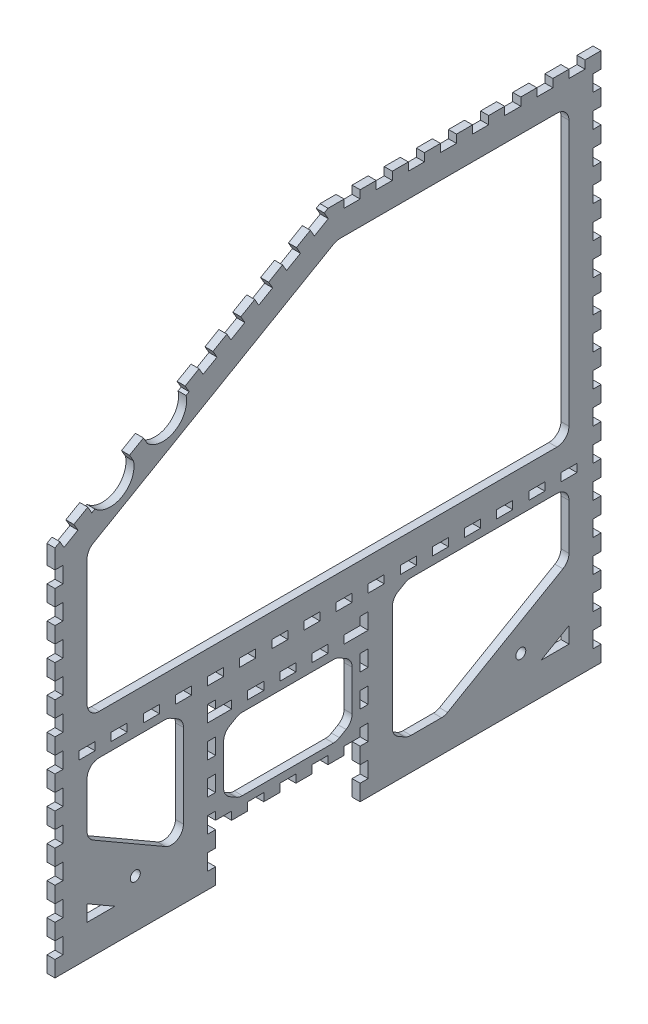
from build123d import *

# Parameters (mm, degrees)
BOSS_EXTRUDE1_DEPTH = 6.35
SKETCH3_R           = 3.96875
CUT_EXTRUDE1_DEPTH  = 7.35
SKETCH5_W           = 6.35
SKETCH5_H           = 12.7
CUT_EXTRUDE3_DEPTH  = 7.35
LPATTERN1_COUNT     = 16
LPATTERN1_PITCH     = 25.4
SKETCH6_W           = 6.35
SKETCH6_H           = 12.7
CUT_EXTRUDE4_DEPTH  = 7.35
LPATTERN2_COUNT     = 11
LPATTERN2_PITCH     = 25.4
SKETCH7_W           = 6.35
SKETCH7_H           = 12.7
SKETCH7_W_2         = 12.7
SKETCH7_H_2         = 6.35
CUT_EXTRUDE5_DEPTH  = 7.35
CUT_EXTRUDE6_DEPTH  = 7.35
LPATTERN3_COUNT     = 10
LPATTERN3_PITCH     = 25.4
SKETCH9_W           = 12.7
SKETCH9_H           = 6.35
CUT_EXTRUDE7_DEPTH  = 7.35
LPATTERN4_COUNT     = 8
LPATTERN4_PITCH     = 25.4
SKETCH10_R          = 3.175
CUT_EXTRUDE8_DEPTH  = 7.35
SKETCH11_R          = 3.96875
CUT_EXTRUDE9_DEPTH  = 7.35
SKETCH12_W          = 6.35
SKETCH12_H          = 12.7
CUT_EXTRUDE13_DEPTH = 7.35
CUT_EXTRUDE15_DEPTH = 7.35
CUT_EXTRUDE16_DEPTH = 7.35
SKETCH17_W          = 12.7
SKETCH17_H          = 6.35
CUT_EXTRUDE17_DEPTH = 7.35
LPATTERN5_COUNT     = 17
LPATTERN5_PITCH     = 25.4
LPATTERN6_COUNT     = 2
LPATTERN6_PITCH     = 120.65
SKETCH18_W          = 12.7
SKETCH18_H          = 6.35
CUT_EXTRUDE18_DEPTH = 7.35
LPATTERN7_COUNT     = 5
LPATTERN7_PITCH     = 25.4
CUT_EXTRUDE19_DEPTH = 7.35
SKETCH20_W          = 101.6
SKETCH20_H          = 57.15
CUT_EXTRUDE20_DEPTH = 7.35
CUT_EXTRUDE21_DEPTH = 7.35
CUT_EXTRUDE22_DEPTH = 7.35
BOSS_EXTRUDE4_DEPTH = 6.35
FILLET1_R           = 9.525


with BuildPart() as part:
    # Sketch2 → Boss-Extrude1 (new body)
    with BuildSketch(Plane(origin=(0, 0, 0), x_dir=(0, 0, -1), z_dir=(1, 0, 0))):
        Polygon((0, 0), (0, 294.450076882), (215.9, 419.1), (431.8, 419.1), (431.8, 0), (241.3, 0), (241.3, 38.1), (127, 38.1), (127, 0), align=None)
    extrude(amount=BOSS_EXTRUDE1_DEPTH)

    # Sketch3 → Cut-Extrude1 (cut, through all)
    with BuildSketch(Plane(origin=(6.35, 0, 0), x_dir=(0, 0, -1), z_dir=(1, 0, 0))):
        with Locations((63.5, 38.1)):
            Circle(SKETCH3_R)
        with Locations((368.3, 38.1)):
            Circle(SKETCH3_R)
    extrude(amount=-CUT_EXTRUDE1_DEPTH, mode=Mode.SUBTRACT)

    # Sketch5 → Cut-Extrude3 (cut, through all)
    with BuildSketch(Plane(origin=(6.35, 0, 0), x_dir=(0, 0, -1), z_dir=(1, 0, 0))):
        with Locations((428.625, 19.05)):
            Rectangle(SKETCH5_W, SKETCH5_H)
    cut_extrude3 = extrude(amount=-CUT_EXTRUDE3_DEPTH, mode=Mode.SUBTRACT)

    # LPattern1: Cut-Extrude3 ×16
    with Locations(*[(0, i * LPATTERN1_PITCH, 0) for i in range(1, LPATTERN1_COUNT)]):
        add(cut_extrude3, mode=Mode.SUBTRACT)

    # Sketch6 → Cut-Extrude4 (cut, through all)
    with BuildSketch(Plane(origin=(6.35, 0, 0), x_dir=(0, 0, -1), z_dir=(1, 0, 0))):
        with Locations((3.175, 19.05)):
            Rectangle(SKETCH6_W, SKETCH6_H)
    cut_extrude4 = extrude(amount=-CUT_EXTRUDE4_DEPTH, mode=Mode.SUBTRACT)

    # LPattern2: Cut-Extrude4 ×11
    with Locations(*[(0, i * LPATTERN2_PITCH, 0) for i in range(1, LPATTERN2_COUNT)]):
        add(cut_extrude4, mode=Mode.SUBTRACT)

    # Sketch7 → Cut-Extrude5 (cut, through all)
    with BuildSketch(Plane(origin=(6.35, 0, 0), x_dir=(0, 0, -1), z_dir=(1, 0, 0))):
        with Locations((123.825, 19.05)):
            Rectangle(SKETCH7_W, SKETCH7_H)
        with Locations((133.35, 41.275)):
            Rectangle(SKETCH7_W_2, SKETCH7_H_2)
        with Locations((158.75, 41.275)):
            Rectangle(SKETCH7_W_2, SKETCH7_H_2)
        with Locations((184.15, 41.275)):
            Rectangle(SKETCH7_W_2, SKETCH7_H_2)
        with Locations((244.475, 19.05)):
            Rectangle(SKETCH7_W, SKETCH7_H)
        with Locations((209.55, 41.275)):
            Rectangle(SKETCH7_W_2, SKETCH7_H_2)
        with Locations((234.95, 41.275)):
            Rectangle(SKETCH7_W_2, SKETCH7_H_2)
    extrude(amount=-CUT_EXTRUDE5_DEPTH, mode=Mode.SUBTRACT)

    # Sketch8 → Cut-Extrude6 (cut, through all)
    with BuildSketch(Plane(origin=(6.35, 0, 0), x_dir=(0, 0, -1), z_dir=(1, 0, 0))):
        Polygon((201.93507044, 411.037344159), (212.933593068, 417.387344159), (216.108593068, 411.888082845), (205.11007044, 405.538082845), align=None)
    cut_extrude6 = extrude(amount=-CUT_EXTRUDE6_DEPTH, mode=Mode.SUBTRACT)

    # LPattern3: Cut-Extrude6 ×10
    with Locations(*[Vector(0, -0.5, 0.866025404) * (i * LPATTERN3_PITCH) for i in range(1, LPATTERN3_COUNT)]):
        add(cut_extrude6, mode=Mode.SUBTRACT)

    # Sketch9 → Cut-Extrude7 (cut, through all)
    with BuildSketch(Plane(origin=(6.35, 0, 0), x_dir=(0, 0, -1), z_dir=(1, 0, 0))):
        with Locations((412.75, 415.925)):
            Rectangle(SKETCH9_W, SKETCH9_H)
    cut_extrude7 = extrude(amount=-CUT_EXTRUDE7_DEPTH, mode=Mode.SUBTRACT)

    # LPattern4: Cut-Extrude7 ×8
    with Locations(*[(0, 0, i * LPATTERN4_PITCH) for i in range(1, LPATTERN4_COUNT)]):
        add(cut_extrude7, mode=Mode.SUBTRACT)

    # Sketch10 → Cut-Extrude8 (cut, through all)
    with BuildSketch(Plane(origin=(6.35, 0, 0), x_dir=(0, 0, -1), z_dir=(1, 0, 0))):
        with Locations((222.25, 273.05)):
            Circle(SKETCH10_R)
        with Locations((222.25, 57.15)):
            Circle(SKETCH10_R)
        with Locations((146.05, 57.15)):
            Circle(SKETCH10_R)
        with Locations((146.05, 273.05)):
            Circle(SKETCH10_R)
    extrude(amount=-CUT_EXTRUDE8_DEPTH, mode=Mode.SUBTRACT)

    # Sketch11 → Cut-Extrude9 (cut, through all)
    with BuildSketch(Plane(origin=(6.35, 0, 0), x_dir=(0, 0, -1), z_dir=(1, 0, 0))):
        with Locations((38.1, 260.35)):
            Circle(SKETCH11_R)
        with Locations((266.7, 260.35)):
            Circle(SKETCH11_R)
    extrude(amount=-CUT_EXTRUDE9_DEPTH, mode=Mode.SUBTRACT)

    # Sketch12 → Cut-Extrude13 (cut, through all)
    with BuildSketch(Plane(origin=(6.35, 0, 0), x_dir=(0, 0, -1), z_dir=(1, 0, 0))):
        with Locations((123.825, 44.45)):
            Rectangle(SKETCH12_W, SKETCH12_H)
        with Locations((123.825, 69.85)):
            Rectangle(SKETCH12_W, SKETCH12_H)
        with Locations((123.825, 95.25)):
            Rectangle(SKETCH12_W, SKETCH12_H)
        with Locations((123.825, 120.65)):
            Rectangle(SKETCH12_W, SKETCH12_H)
    cut_extrude13 = extrude(amount=-CUT_EXTRUDE13_DEPTH, mode=Mode.SUBTRACT)

    # Sketch14 → Cut-Extrude15 (cut, through all)
    with BuildSketch(Plane(origin=(6.35, 0, 0), x_dir=(0, 0, -1), z_dir=(1, 0, 0))):
        Polygon((36.957231019, 315.787344159), (47.955753647, 322.137344159), (51.130753647, 316.638082845), (40.132231019, 310.288082845), align=None)
        Polygon((80.951321531, 341.187344159), (91.949844159, 347.537344159), (95.124844159, 342.038082845), (84.126321531, 335.688082845), align=None)
    extrude(amount=-CUT_EXTRUDE15_DEPTH, mode=Mode.SUBTRACT)

    # Sketch15 → Cut-Extrude16 (cut, through all)
    with BuildSketch(Plane(origin=(6.35, 0, 0), x_dir=(0, 0, -1), z_dir=(1, 0, 0))):
        with BuildLine():
            Line((62.129276275, 322.988082845), (31.558579521, 305.338082845))
            ThreePointArc((31.558579521, 305.338082845), (51.535904978, 302.314952438), (62.501260575, 319.285333297))
            ThreePointArc((62.501260575, 319.285333297), (62.408031035, 321.146027155), (62.129276275, 322.988082845))
        make_face()
        with BuildLine():
            Line((103.698495657, 346.988082845), (73.127798903, 329.338082845))
            ThreePointArc((73.127798903, 329.338082845), (93.10512436, 326.314952438), (104.070479957, 343.285333297))
            ThreePointArc((104.070479957, 343.285333297), (103.977250417, 345.146027155), (103.698495657, 346.988082845))
        make_face()
    extrude(amount=-CUT_EXTRUDE16_DEPTH, mode=Mode.SUBTRACT)

    # Sketch17 → Cut-Extrude17 (cut, through all)
    with BuildSketch(Plane(origin=(6.35, 0, 0), x_dir=(0, 0, -1), z_dir=(1, 0, 0))):
        with Locations((25.4, 142.875)):
            Rectangle(SKETCH17_W, SKETCH17_H)
    cut_extrude17 = extrude(amount=-CUT_EXTRUDE17_DEPTH, mode=Mode.SUBTRACT)

    # LPattern5: Cut-Extrude17 ×17
    with Locations(*[(0, 0, -i * LPATTERN5_PITCH) for i in range(1, LPATTERN5_COUNT)]):
        add(cut_extrude17, mode=Mode.SUBTRACT)

    # LPattern6: Cut-Extrude13 ×2
    with Locations(*[(0, 0, -i * LPATTERN6_PITCH) for i in range(1, LPATTERN6_COUNT)]):
        add(cut_extrude13, mode=Mode.SUBTRACT)

    # Sketch18 → Cut-Extrude18 (cut, through all)
    with BuildSketch(Plane(origin=(6.35, 0, 0), x_dir=(0, 0, -1), z_dir=(1, 0, 0))):
        with Locations((133.35, 117.475)):
            Rectangle(SKETCH18_W, SKETCH18_H)
    cut_extrude18 = extrude(amount=-CUT_EXTRUDE18_DEPTH, mode=Mode.SUBTRACT)

    # LPattern7: Cut-Extrude18 ×5
    with Locations(*[(0, 0, -i * LPATTERN7_PITCH) for i in range(1, LPATTERN7_COUNT)]):
        add(cut_extrude18, mode=Mode.SUBTRACT)

    # Sketch19 → Cut-Extrude19 (cut, through all)
    with BuildSketch(Plane(origin=(6.35, 0, 0), x_dir=(0, 0, -1), z_dir=(1, 0, 0))):
        Polygon((25.4, 279.785380045), (222.705909488, 393.7), (406.4, 393.7), (406.4, 165.1), (25.4, 165.1), align=None)
    extrude(amount=-CUT_EXTRUDE19_DEPTH, mode=Mode.SUBTRACT)

    # Sketch20 → Cut-Extrude20 (cut, through all)
    with BuildSketch(Plane(origin=(6.35, 0, 0), x_dir=(0, 0, -1), z_dir=(1, 0, 0))):
        with Locations((184.15, 79.375)):
            Rectangle(SKETCH20_W, SKETCH20_H)
    extrude(amount=-CUT_EXTRUDE20_DEPTH, mode=Mode.SUBTRACT)

    # Sketch21 → Cut-Extrude21 (cut, through all)
    with BuildSketch(Plane(origin=(6.35, 0, 0), x_dir=(0, 0, -1), z_dir=(1, 0, 0))):
        Polygon((266.7, 25.4), (308.202954744, 25.4), (406.4, 82.094090512), (406.4, 133.35), (266.7, 133.35), align=None)
        Polygon((25.4, 133.35), (25.4, 82.094090512), (101.6, 38.1), (101.6, 133.35), align=None)
        Polygon((25.4, 38.1), (25.4, 25.4), (47.397045256, 25.4), align=None)
    extrude(amount=-CUT_EXTRUDE21_DEPTH, mode=Mode.SUBTRACT)

    # Sketch22 → Cut-Extrude22 (cut, through all)
    with BuildSketch(Plane(origin=(6.35, 0, 0), x_dir=(0, 0, -1), z_dir=(1, 0, 0))):
        Polygon((384.402954744, 25.4), (406.4, 38.1), (406.4, 25.4), align=None)
    extrude(amount=-CUT_EXTRUDE22_DEPTH, mode=Mode.SUBTRACT)

    # Sketch26 → Boss-Extrude4 (add, through all)
    with BuildSketch(Plane(origin=(6.35, 0, 0), x_dir=(0, 0, -1), z_dir=(1, 0, 0))):
        Polygon((266.7, 133.35), (266.7, 126.280871047), (278.944090512, 133.35), align=None)
        Polygon((89.355909488, 133.35), (101.6, 126.280871047), (101.6, 133.35), align=None)
        Polygon((266.7, 32.469128953), (278.944090512, 25.4), (266.7, 25.4), align=None)
        Polygon((133.35, 107.95), (133.35, 100.880871047), (145.594090512, 107.95), align=None)
        Polygon((234.95, 107.95), (222.705909488, 107.95), (234.95, 100.880871047), align=None)
        Polygon((133.35, 50.8), (145.594090512, 50.8), (133.35, 57.869128953), align=None)
        Polygon((234.95, 50.8), (222.705909488, 50.8), (234.95, 57.869128953), align=None)
    extrude(amount=-BOSS_EXTRUDE4_DEPTH)

    # Fillet1
    fillet1_edges = [part.edges().sort_by_distance(p)[0] for p in [
        (3.175, 165.1, -25.4),
        (3.175, 279.785380045, -25.4),
        (3.175, 393.7, -222.705909488),
        (3.175, 393.7, -406.4),
        (3.175, 165.1, -406.4),
        (3.175, 133.35, -406.4),
        (3.175, 82.094090512, -406.4),
        (3.175, 25.4, -308.202954744),
        (3.175, 133.35, -25.4),
        (3.175, 38.1, -101.6),
        (3.175, 82.094090512, -25.4),
        (3.175, 133.35, -278.944090512),
        (3.175, 126.280871047, -266.7),
        (3.175, 100.880871047, -234.95),
        (3.175, 107.95, -222.705909488),
        (3.175, 133.35, -89.355909488),
        (3.175, 126.280871047, -101.6),
        (3.175, 32.469128953, -266.7),
        (3.175, 25.4, -278.944090512),
        (3.175, 107.95, -145.594090512),
        (3.175, 100.880871047, -133.35),
        (3.175, 57.869128953, -133.35),
        (3.175, 50.8, -145.594090512),
        (3.175, 57.869128953, -234.95),
        (3.175, 50.8, -222.705909488),
    ]]
    fillet(fillet1_edges, radius=FILLET1_R)


solid = part.part
